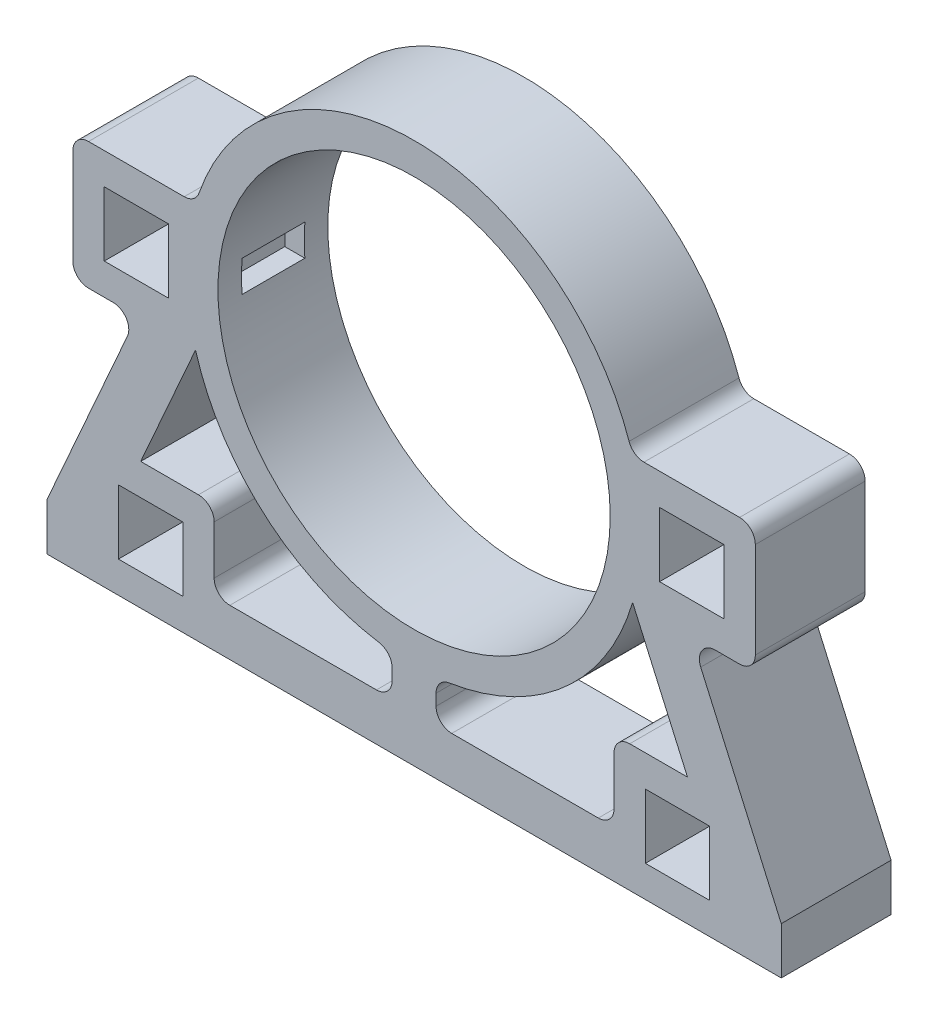
from build123d import *

# Parameters (mm, degrees)
SKETCH1_W           = 20.5
SKETCH1_H           = 20.5
SKETCH1_R           = 62.5
BOSS_EXTRUDE1_DEPTH = 35
FILLET2_R           = 5
SKETCH2_W           = 20
SKETCH2_H           = 10
CUT_EXTRUDE2_DEPTH  = 7
SKETCH3_W           = 20
SKETCH3_H           = 10
CUT_EXTRUDE3_DEPTH  = 7


with BuildPart() as part:
    # Sketch1 → Boss-Extrude1 (new body)
    with BuildSketch(Plane.XY):
        with BuildLine():
            Line((117, -100.161277705), (117, -85.161277705))
            Line((117, -85.161277705), (88.226517383, -20.181680312))
            Line((88.226517383, -20.181680312), (108.734784021, -20.181680312))
            Line((108.734784021, -20.181680312), (108.734784021, 20.318319688))
            Line((108.734784021, 20.318319688), (69.594654141, 20.318319688))
            ThreePointArc((69.594654141, 20.318319688), (0, 72.5), (-69.594654141, 20.318319688))
            Line((-69.594654141, 20.318319688), (-108.734784021, 20.318319688))
            Line((-108.734784021, 20.318319688), (-108.734784021, -20.181680312))
            Line((-108.734784021, -20.181680312), (-88.226517383, -20.181680312))
            Line((-88.226517383, -20.181680312), (-117, -85.161277705))
            Line((-117, -85.161277705), (-117, -100.161277705))
            Line((-117, -100.161277705), (117, -100.161277705))
        make_face()
        with Locations((83.958397156, -79.911277705)):
            Rectangle(SKETCH1_W, SKETCH1_H, mode=Mode.SUBTRACT)
        with Locations((-83.958397156, -79.911277705)):
            Rectangle(SKETCH1_W, SKETCH1_H, mode=Mode.SUBTRACT)
        with BuildLine():
            Line((-63.708397156, -59.661277705), (-87.116280609, -59.661277705))
            Line((-87.116280609, -59.661277705), (-69.634400836, -20.181680312))
            ThreePointArc((-69.634400836, -20.181680312), (-46.29986484, -55.79043391), (-7, -72.161277705))
            Line((-7, -72.161277705), (-7, -85.161277705))
            Line((-7, -85.161277705), (-63.708397156, -85.161277705))
            Line((-63.708397156, -85.161277705), (-63.708397156, -59.661277705))
        make_face(mode=Mode.SUBTRACT)
        with BuildLine():
            Line((87.116280609, -59.661277705), (63.708397156, -59.661277705))
            Line((63.708397156, -59.661277705), (63.708397156, -85.161277705))
            Line((63.708397156, -85.161277705), (7, -85.161277705))
            Line((7, -85.161277705), (7, -72.161277705))
            ThreePointArc((7, -72.161277705), (46.29986484, -55.79043391), (69.634400836, -20.181680312))
            Line((69.634400836, -20.181680312), (87.116280609, -59.661277705))
        make_face(mode=Mode.SUBTRACT)
        with Locations((-88.484784021, 0.068319688)):
            Rectangle(SKETCH1_W, SKETCH1_H, mode=Mode.SUBTRACT)
        Circle(SKETCH1_R, mode=Mode.SUBTRACT)
        with Locations((88.484784021, 0.068319688)):
            Rectangle(SKETCH1_W, SKETCH1_H, mode=Mode.SUBTRACT)
    extrude(amount=BOSS_EXTRUDE1_DEPTH)

    # Fillet2
    fillet2_edges = [part.edges().sort_by_distance(p)[0] for p in [
        (-88.226517383, -20.181680312, 17.5),
        (-108.734784021, -20.181680312, 17.5),
        (-108.734784021, 20.318319688, 17.5),
        (-69.594654141, 20.318319688, 17.5),
        (69.594654141, 20.318319688, 17.5),
        (108.734784021, 20.318319688, 17.5),
        (108.734784021, -20.181680312, 17.5),
        (88.226517383, -20.181680312, 17.5),
        (7, -72.161277705, 17.5),
        (7, -85.161277705, 17.5),
        (63.708397156, -85.161277705, 17.5),
        (63.708397156, -59.661277705, 17.5),
        (-63.708397156, -59.661277705, 17.5),
        (-63.708397156, -85.161277705, 17.5),
        (-7, -85.161277705, 17.5),
        (-7, -72.161277705, 17.5),
    ]]
    fillet(fillet2_edges, radius=FILLET2_R)

    # Sketch2 → Cut-Extrude2 (cut)
    with BuildSketch(Plane(origin=(61.7, 0, 0), x_dir=(0, 0, -1), z_dir=(1, 0, 0))):
        with Locations((-17.5, 0.068319688)):
            Rectangle(SKETCH2_W, SKETCH2_H)
    extrude(amount=CUT_EXTRUDE2_DEPTH, mode=Mode.SUBTRACT)

    # Sketch3 → Cut-Extrude3 (cut)
    with BuildSketch(Plane(origin=(-61.7, 0, 0), x_dir=(0, 0, -1), z_dir=(1, 0, 0))):
        with Locations((-17.5, 0.068319688)):
            Rectangle(SKETCH3_W, SKETCH3_H)
    extrude(amount=-CUT_EXTRUDE3_DEPTH, mode=Mode.SUBTRACT)


solid = part.part
